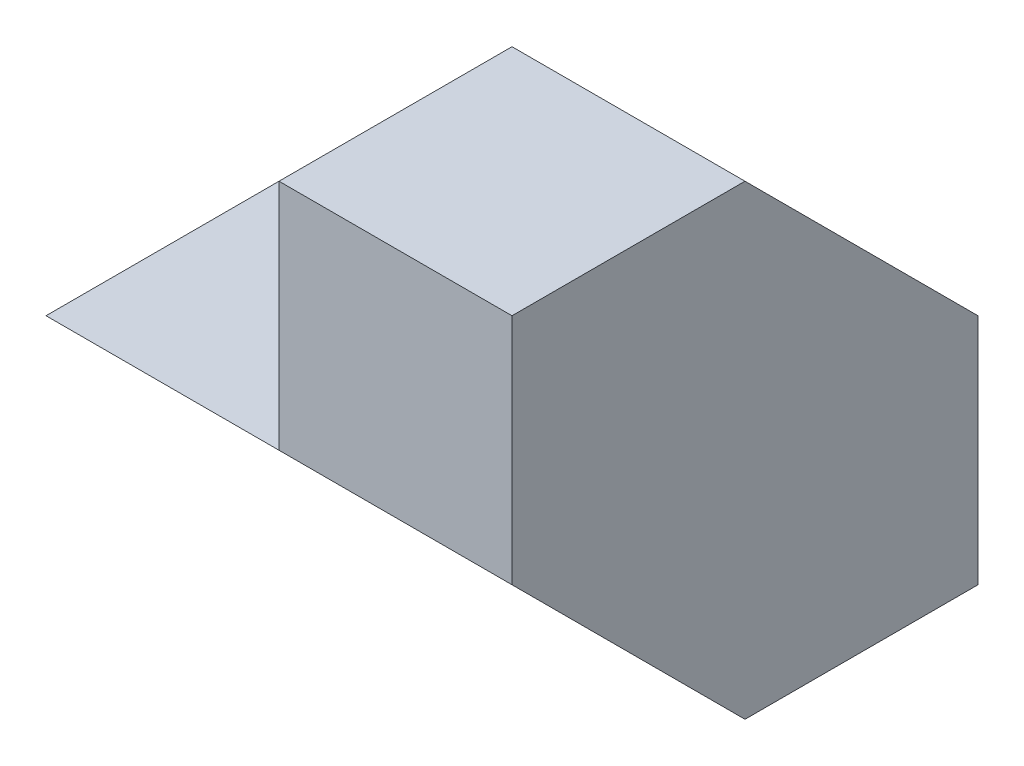
from build123d import *

# Parameters (mm, degrees)
SKETCH1_W           = 40
SKETCH1_H           = 20
BOSS_EXTRUDE1_DEPTH = 40
CUT_EXTRUDE1_DEPTH  = 40
SKETCH4_W           = 20
SKETCH4_H           = 20
BOSS_EXTRUDE3_DEPTH = 40
CUT_EXTRUDE2_DEPTH  = 40


with BuildPart() as part:
    # Sketch1 → Boss-Extrude1 (new body)
    with BuildSketch(Plane.XY):
        with Locations((20, 10)):
            Rectangle(SKETCH1_W, SKETCH1_H)
    extrude(amount=BOSS_EXTRUDE1_DEPTH)

    # Sketch2 → Cut-Extrude1 (cut)
    with BuildSketch(Plane.ZY):
        Polygon((40, 20), (20, 0), (40, 0), align=None)
    extrude(amount=-CUT_EXTRUDE1_DEPTH, mode=Mode.SUBTRACT)

    # Sketch4 → Boss-Extrude3 (add)
    with BuildSketch(Plane(origin=(0, 0, 0), x_dir=(-1, 0, 0), z_dir=(0, 0, -1))):
        with Locations((-30, 30)):
            Rectangle(SKETCH4_W, SKETCH4_H)
    extrude(amount=-BOSS_EXTRUDE3_DEPTH)

    # Sketch5 → Cut-Extrude2 (cut)
    with BuildSketch(Plane.ZY.offset(-20)):
        Polygon((0, 20), (20, 40), (0, 40), align=None)
    extrude(amount=-CUT_EXTRUDE2_DEPTH, mode=Mode.SUBTRACT)


solid = part.part
